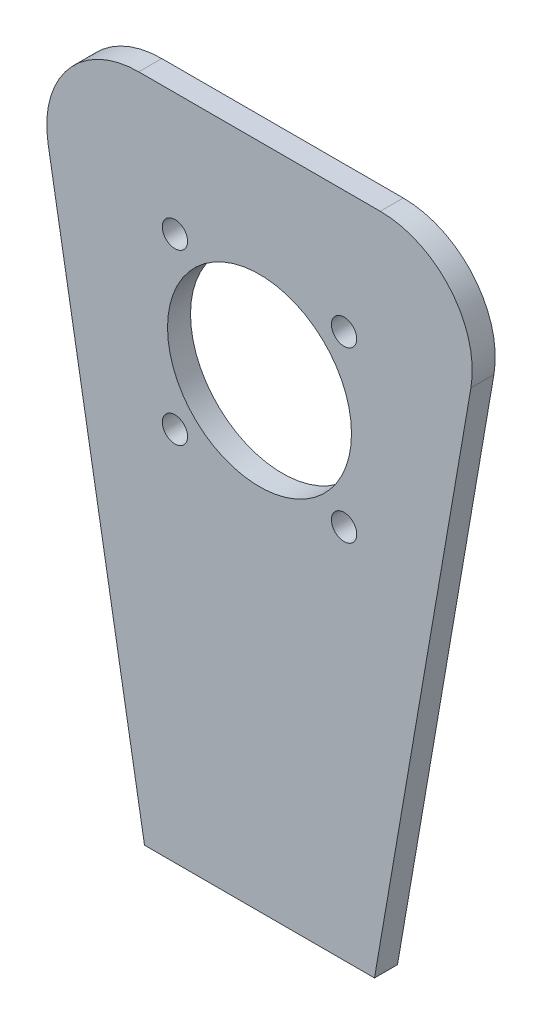
from build123d import *

# Parameters (mm, degrees)
SKETCH1_R           = 20
SKETCH1_R_2         = 2.75
BOSS_EXTRUDE1_DEPTH = 5
FILLET1_R           = 20


with BuildPart() as part:
    # Sketch1 → Boss-Extrude1 (new body)
    with BuildSketch(Plane.XY):
        Polygon((25, 0), (-25, 0), (-50, 145), (50, 145), align=None)
        with Locations((0, 100)):
            Circle(SKETCH1_R, mode=Mode.SUBTRACT)
        with Locations((-18.384776311, 118.384776311)):
            Circle(SKETCH1_R_2, mode=Mode.SUBTRACT)
        with Locations((-18.384776311, 81.615223689)):
            Circle(SKETCH1_R_2, mode=Mode.SUBTRACT)
        with Locations((18.384776311, 81.615223689)):
            Circle(SKETCH1_R_2, mode=Mode.SUBTRACT)
        with Locations((18.384776311, 118.384776311)):
            Circle(SKETCH1_R_2, mode=Mode.SUBTRACT)
    extrude(amount=BOSS_EXTRUDE1_DEPTH)

    # Fillet1
    fillet1_edges = [part.edges().sort_by_distance(p)[0] for p in [
        (-50, 145, 2.5),
        (50, 145, 2.5),
    ]]
    fillet(fillet1_edges, radius=FILLET1_R)


solid = part.part
